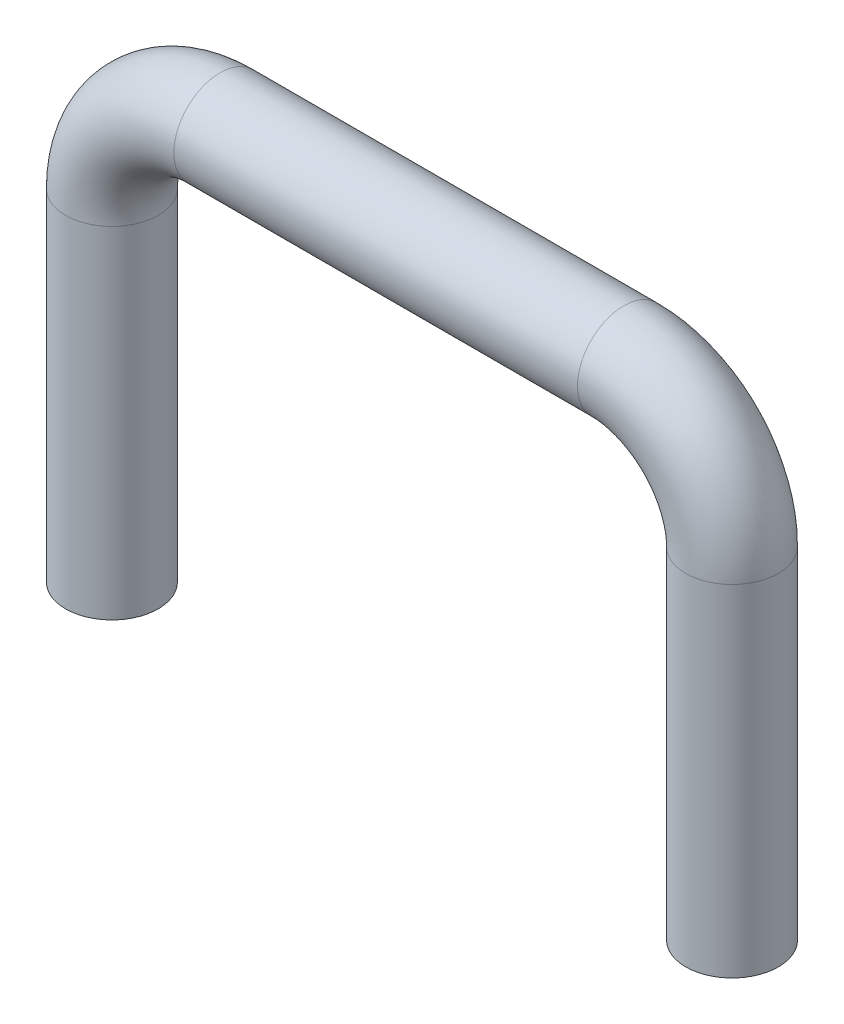
from build123d import *

# Parameters (mm, degrees)
SKETCH3_R = 2.3749


with BuildPart() as part:
    # Sweep1: sweep along a path in Sketch4
    with BuildLine(Plane.XY) as sweep1_path:
        Line((0, 23.0251), (-10.35, 23.0251))
        ThreePointArc((-10.35, 23.0251), (-14.274371925, 21.399571925), (-15.8999, 17.4752))
        Line((-15.8999, 17.4752), (-15.8999, 0))
    # Sketch3 → Sweep1 (sweep)
    with BuildSketch(Plane(origin=(0, 0, 0), x_dir=(1, 0, 0), z_dir=(0, 1, 0))):
        with Locations((-15.8999, 0)):
            Circle(SKETCH3_R)
    sweep(path=sweep1_path.line)

    # Mirror1: part across plane


with BuildPart() as part_1:
    add(part.part)
    add(part.part.mirror(Plane(origin=(0, 0, 0), x_dir=(0, 0, 1), z_dir=(1, 0, 0))))


solid = part_1.part
